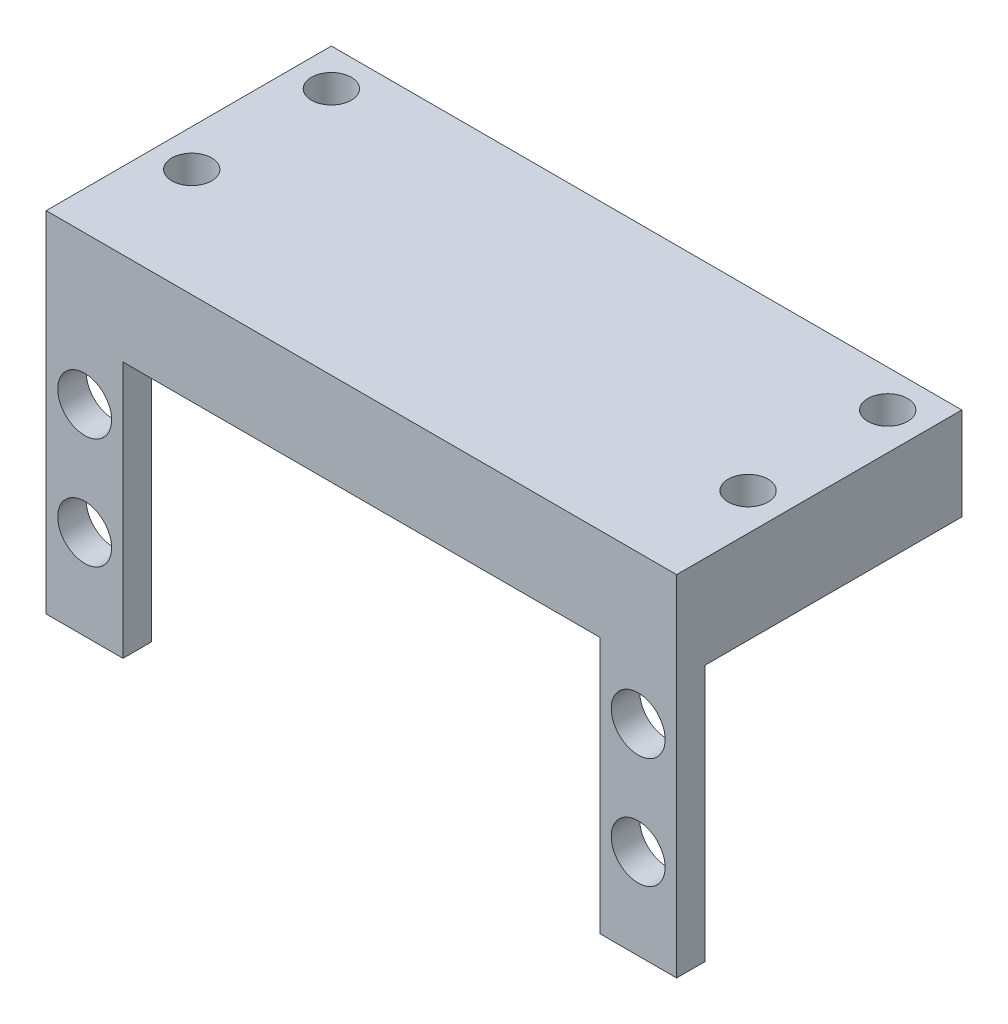
from build123d import *

# Parameters (mm, degrees)
SKETCH1_W           = 56.15
SKETCH1_H           = 25.4
BOSS_EXTRUDE1_DEPTH = 2.54
SKETCH2_W           = 56.15
SKETCH2_H           = 25.4
BOSS_EXTRUDE2_DEPTH = 2.54
SKETCH3_R           = 2.400000018
CUT_EXTRUDE1_DEPTH  = 26.4
SKETCH11_W          = 56.15
SKETCH11_H          = 25.4
BOSS_EXTRUDE3_DEPTH = 5.715
SKETCH6_R           = 1.774
CUT_EXTRUDE3_DEPTH  = 9.255
CUT_EXTRUDE4_DEPTH  = 26.4


with BuildPart() as part:
    # Sketch1 → Boss-Extrude1 (new body)
    with BuildSketch(Plane(origin=(0, 0, 0), x_dir=(1, 0, 0), z_dir=(0, 1, 0))):
        with Locations((28.075, 12.7)):
            Rectangle(SKETCH1_W, SKETCH1_H)
    extrude(amount=-BOSS_EXTRUDE1_DEPTH)

    # Sketch2 → Boss-Extrude2 (add)
    with BuildSketch(Plane.XY):
        with Locations((28.075, -12.7)):
            Rectangle(SKETCH2_W, SKETCH2_H)
    extrude(amount=-BOSS_EXTRUDE2_DEPTH)

    # Sketch3 → Cut-Extrude1 (cut, through all)
    with BuildSketch(Plane.XY):
        with Locations((3.425, -7.515)):
            Circle(SKETCH3_R)
        with Locations((3.425, -17.385)):
            Circle(SKETCH3_R)
        with Locations((52.725, -7.515)):
            Circle(SKETCH3_R)
        with Locations((52.725, -17.385)):
            Circle(SKETCH3_R)
    extrude(amount=-CUT_EXTRUDE1_DEPTH, mode=Mode.SUBTRACT)

    # Sketch11 → Boss-Extrude3 (add)
    with BuildSketch(Plane(origin=(0, 0, 0), x_dir=(1, 0, 0), z_dir=(0, 1, 0))):
        with Locations((28.075, 12.7)):
            Rectangle(SKETCH11_W, SKETCH11_H)
    extrude(amount=BOSS_EXTRUDE3_DEPTH)

    # Sketch6 → Cut-Extrude3 (cut, through all)
    with BuildSketch(Plane.XZ.offset(2.54)):
        with Locations((52.852, -22.102)):
            Circle(SKETCH6_R)
        with Locations((52.852, -9.664)):
            Circle(SKETCH6_R)
        with Locations((3.298, -9.664)):
            Circle(SKETCH6_R)
        with Locations((3.298, -22.102)):
            Circle(SKETCH6_R)
    extrude(amount=-CUT_EXTRUDE3_DEPTH, mode=Mode.SUBTRACT)

    # Sketch7 → Cut-Extrude4 (cut, through all)
    with BuildSketch(Plane.XY):
        Polygon((49.308999982, -2.54), (6.841000018, -2.54), (6.841000018, -7.515), (6.841000018, -25.4), (49.308999982, -25.4), align=None)
    extrude(amount=-CUT_EXTRUDE4_DEPTH, mode=Mode.SUBTRACT)


solid = part.part
